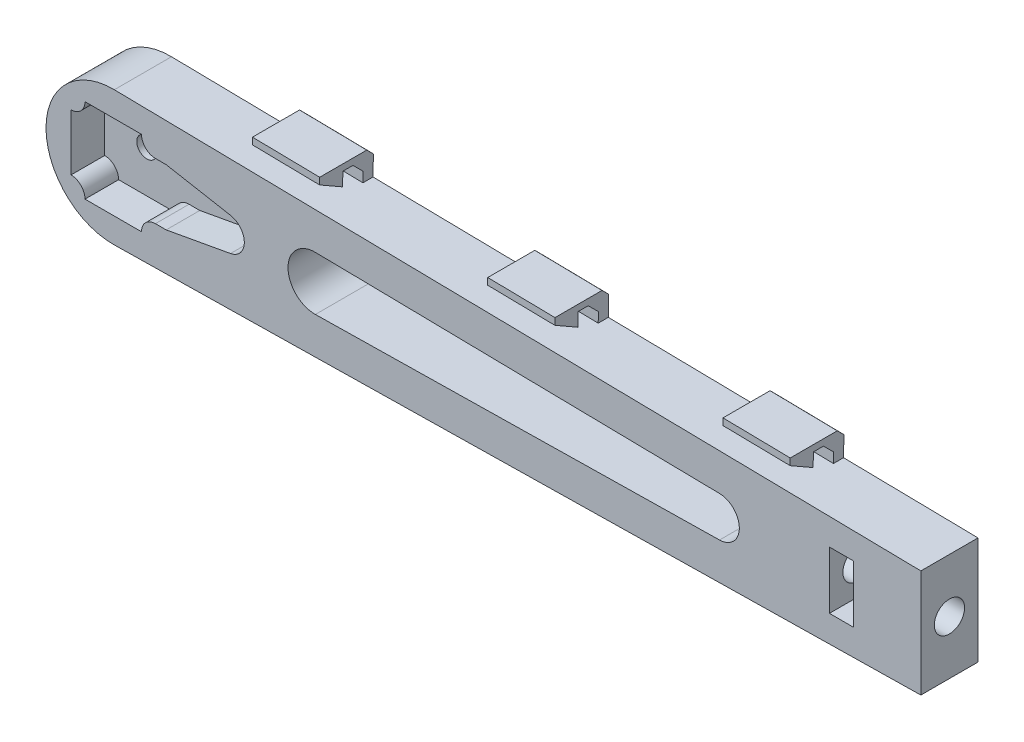
from build123d import *

# Parameters (mm, degrees)
AUFSATZ_LINEAR_AUSTRAGEN1_DEPTH = 8.5
CUT_EXTRUDE4_DEPTH              = 5
SKETCH2_R                       = 1.5
CUT_EXTRUDE5_DEPTH              = 9.5
CUT_EXTRUDE6_DEPTH              = 9.5
SKETCH3_W                       = 3.6
SKETCH3_H                       = 7.3
CUT_EXTRUDE9_DEPTH              = 7.95
SKETCH4_R                       = 2.25
CUT_EXTRUDE10_DEPTH             = 20
BOSS_EXTRUDE1_START             = -20
BOSS_EXTRUDE1_DEPTH             = 10
AUFSATZ_LINEAR_AUSTRAGEN2_DEPTH = 3.6
SCHNITT_LINEAR_AUSTRAGEN1_DEPTH = 3.6
LPATTERN1_COUNT                 = 3
LPATTERN1_PITCH                 = 35
SKIZZE4_R                       = 3.25
SCHNITT_LINEAR_AUSTRAGEN2_DEPTH = 2


with BuildPart() as part:
    # Skizze1 → Aufsatz-Linear austragen1 (new body)
    with BuildSketch(Plane.XY):
        with BuildLine():
            Line((120.133333333, 7.998888812), (0.166666667, 9.998611015))
            ThreePointArc((0.166666667, 9.998611015), (-10, 0), (0.166666667, -9.998611015))
            Line((0.166666667, -9.998611015), (120.133333333, -7.998888812))
            Line((120.133333333, -7.998888812), (120.133333333, 7.998888812))
        make_face()
    extrude(amount=AUFSATZ_LINEAR_AUSTRAGEN1_DEPTH)

    # Sketch1 → Cut-Extrude4 (cut)
    with BuildSketch(Plane.XY.offset(8.5)):
        with BuildLine():
            Line((-4.200128323, -6.276826928), (4.200128323, -6.276826928))
            ThreePointArc((4.200128323, -6.276826928), (4.808454435, -4.808197778), (6.277083585, -4.199871666))
            Line((6.277083585, -4.199871666), (7.877083585, -4.199871666))
            Line((7.877083585, -4.199871666), (17.44738825, -2.459668071))
            ThreePointArc((17.44738825, -2.459668071), (19.500137785, 0), (17.44738825, 2.459668071))
            Line((17.44738825, 2.459668071), (7.877083585, 4.199871666))
            Line((7.877083585, 4.199871666), (6.277083585, 4.199871666))
            ThreePointArc((6.277083585, 4.199871666), (4.808454435, 4.808197778), (4.200128323, 6.276826928))
            Line((4.200128323, 6.276826928), (-4.200128323, 6.276826928))
            ThreePointArc((-4.200128323, 6.276826928), (-4.808454435, 4.808197778), (-6.277083585, 4.199871666))
            Line((-6.277083585, 4.199871666), (-6.277083585, -4.199871666))
            ThreePointArc((-6.277083585, -4.199871666), (-4.808454435, -4.808197778), (-4.200128323, -6.276826928))
        make_face()
    extrude(amount=-CUT_EXTRUDE4_DEPTH, mode=Mode.SUBTRACT)

    # Sketch2 → Cut-Extrude5 (cut, through all)
    with BuildSketch(Plane(origin=(0, 0, 0), x_dir=(-1, 0, 0), z_dir=(0, 0, -1))):
        Circle(SKETCH2_R)
    extrude(amount=-CUT_EXTRUDE5_DEPTH, mode=Mode.SUBTRACT)

    # Skizze2 → Cut-Extrude6 (cut, through all)
    with BuildSketch(Plane.XY.offset(8.5)):
        with BuildLine():
            Line((90.183296296, 2.997361391), (30.066666667, 3.999444406))
            ThreePointArc((30.066666667, 3.999444406), (26, 0), (30.066666667, -3.999444406))
            Line((30.066666667, -3.999444406), (90.183296296, -2.997361391))
            ThreePointArc((90.183296296, -2.997361391), (93.131111111, 0), (90.183296296, 2.997361391))
        make_face()
    extrude(amount=-CUT_EXTRUDE6_DEPTH, mode=Mode.SUBTRACT)

    # Sketch3 → Cut-Extrude9 (cut)
    with BuildSketch(Plane.XY.offset(8.5)):
        with Locations((108.333333333, 0)):
            Rectangle(SKETCH3_W, SKETCH3_H)
    extrude(amount=-CUT_EXTRUDE9_DEPTH, mode=Mode.SUBTRACT)

    # Sketch4 → Cut-Extrude10 (cut)
    with BuildSketch(Plane(origin=(120.133333333, 0, 0), x_dir=(0, 0, -1), z_dir=(1, 0, 0))):
        with Locations((-4.25, 0)):
            Circle(SKETCH4_R)
    extrude(amount=-CUT_EXTRUDE10_DEPTH, mode=Mode.SUBTRACT)

    # Sketch5 → Boss-Extrude1 (add)
    with BuildSketch(Plane(origin=(119.966666667, -1.999722203, 0), x_dir=(0, 0, -1), z_dir=(0.999861101, -0.016666667, 0)).offset(BOSS_EXTRUDE1_START)):
        Polygon((0, 10), (0, 13), (-1, 14), (-8, 14), (-8, 13), (-4.541308146, 11), (-4.541308146, 13.041308146), (-3.041308146, 13.041308146), (-1.5, 11.5), (-1.5, 10), align=None)
    boss_extrude1 = extrude(amount=-BOSS_EXTRUDE1_DEPTH)

    # Skizze3 → Aufsatz-Linear austragen2 (add)
    with BuildSketch(Plane(origin=(106.533333333, 0, 0), x_dir=(0, 0, -1), z_dir=(1, 0, 0))):
        Polygon((-0.55, 3.65), (-3.171985448, 3.65), (-0.55, 2.136195996), align=None)
        Polygon((-0.55, -3.65), (-0.55, -2.136195996), (-3.171985448, -3.65), align=None)
    extrude(amount=AUFSATZ_LINEAR_AUSTRAGEN2_DEPTH)

    # Skizze3_3 → Schnitt-Linear austragen1 (cut)
    with BuildSketch(Plane(origin=(106.533333333, 0, 0), x_dir=(0, 0, -1), z_dir=(1, 0, 0))):
        Polygon((-5.328014552, 3.65), (-4.25, 4.272391992), (-8.5, 4.272391992), (-8.5, 3.65), align=None)
        Polygon((-3.171985448, 3.65), (-4.25, 4.272391992), (-5.328014552, 3.65), align=None)
        Polygon((-3.171985448, -3.65), (-5.328014552, -3.65), (-4.25, -4.272391992), align=None)
        Polygon((-5.328014552, -3.65), (-8.5, -3.65), (-8.5, -4.272391992), (-4.25, -4.272391992), align=None)
    extrude(amount=SCHNITT_LINEAR_AUSTRAGEN1_DEPTH, mode=Mode.SUBTRACT)

    # LPattern1: Boss-Extrude1 ×3
    with Locations(*[Vector(-0.999861101, 0.016666667, 0) * (i * LPATTERN1_PITCH) for i in range(1, LPATTERN1_COUNT)]):
        add(boss_extrude1)

    # Skizze4 → Schnitt-Linear austragen2 (cut)
    with BuildSketch(Plane(origin=(0, 0, 0), x_dir=(-1, 0, 0), z_dir=(0, 0, -1))):
        Circle(SKIZZE4_R)
    extrude(amount=-SCHNITT_LINEAR_AUSTRAGEN2_DEPTH, mode=Mode.SUBTRACT)


solid = part.part
